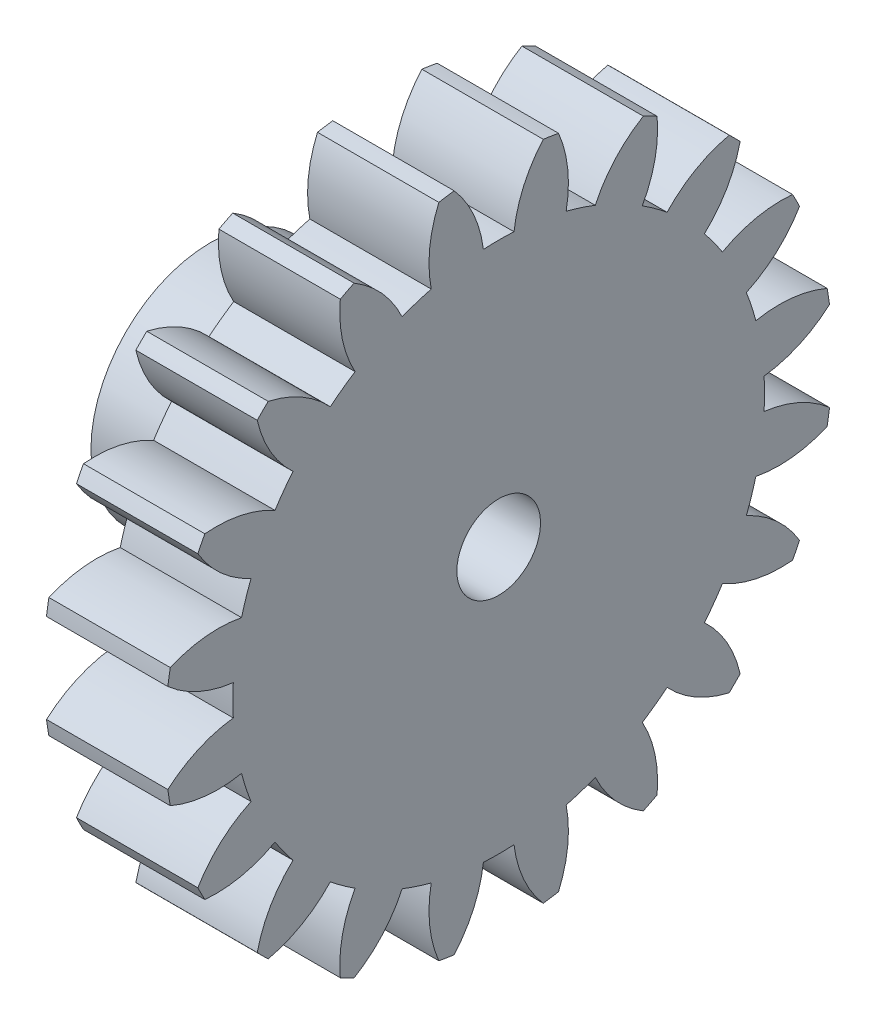
from build123d import *

# Parameters (mm, degrees)
BASPROSKE_W         = 5.08
BASPROSKE_H         = 13.97
TOOTHCUT_DEPTH      = 21.399220573
TEETHCUTS_COUNT     = 20
TEETHCUTS_ANGLE     = 342
BORSKE_R            = 1.750000056
BORE_DEPTH          = 50.8000508
SKETCH1_R           = 5
SKETCH1_R_2         = 1.750000056
BOSS_EXTRUDE1_DEPTH = 6.985
SKETCH3_R           = 3
CUT_EXTRUDE1_DEPTH  = 3.81
BOSS_EXTRUDE2_DEPTH = 3.81
CIRPATTERN1_COUNT   = 36


with BuildPart() as part:
    # BasProSke → Base-Revolve (revolve)
    with BuildSketch(Plane(origin=(0, 0, 0), x_dir=(1, 0, 0), z_dir=(0, 1, 0)), mode=Mode.PRIVATE) as base_revolve_sk:
        with Locations((2.54, 6.985)):
            Rectangle(BASPROSKE_W, BASPROSKE_H)
    revolve(base_revolve_sk.sketch.rotate(Axis((-10, 0, 0), (1, 0, 0)), 180), axis=Axis((-10, 0, 0), (1, 0, 0)))

    # TooCutSke → ToothCut (cut, through all)
    with BuildSketch(Plane(origin=(0, 0, 0), x_dir=(0, 0, -1), z_dir=(1, 0, 0))):
        with BuildLine():
            ThreePointArc((0.64046545, 11.106749257), (0, 11.1252), (-0.64046545, 11.106749257))
            ThreePointArc((-0.64046545, 11.106749257), (-1.052455812, 12.582227662), (-1.8855699, 13.867798935))
            ThreePointArc((-1.8855699, 13.867798935), (0, 13.9954), (1.8855699, 13.867798935))
            ThreePointArc((1.8855699, 13.867798935), (1.052455812, 12.582227662), (0.64046545, 11.106749257))
        make_face()
    toothcut = extrude(amount=TOOTHCUT_DEPTH, mode=Mode.SUBTRACT)

    # TeethCuts: ToothCut ×20 about axis
    teethcuts_axis = Axis((-10, 0, 0), (1, 0, 0))
    for i in range(1, TEETHCUTS_COUNT):
        add(toothcut.rotate(teethcuts_axis, i * TEETHCUTS_ANGLE / (TEETHCUTS_COUNT - 1)), mode=Mode.SUBTRACT)

    # BorSke → Bore (cut, symmetric)
    with BuildSketch(Plane(origin=(0, 0, 0), x_dir=(0, 0, -1), z_dir=(1, 0, 0))):
        with Locations(Location((0, 0, 0), (0, 0, 180))):
            Circle(BORSKE_R)
    extrude(amount=BORE_DEPTH, both=True, mode=Mode.SUBTRACT)

    # Sketch1 → Boss-Extrude1 (add)
    with BuildSketch(Plane.ZY):
        with Locations(Location((0, 0, 0), (0, 0, 180))):
            Circle(SKETCH1_R)
        Circle(SKETCH1_R_2, mode=Mode.SUBTRACT)
    extrude(amount=BOSS_EXTRUDE1_DEPTH)

    # Sketch3 → Cut-Extrude1 (cut)
    with BuildSketch(Plane.ZY.offset(6.985)):
        Circle(SKETCH3_R)
    extrude(amount=-CUT_EXTRUDE1_DEPTH, mode=Mode.SUBTRACT)

    # Sketch4 → Boss-Extrude2 (add)
    with BuildSketch(Plane.ZY.offset(6.985)):
        Polygon((-0.25, 3.127), (0.25, 3.127), (0, 2.693987298), align=None)
    boss_extrude2 = extrude(amount=-BOSS_EXTRUDE2_DEPTH)

    # CirPattern1: Boss-Extrude2 ×36 about axis
    cirpattern1_axis = Axis((0, 0, 0), (1, 0, 0))
    for i in range(1, CIRPATTERN1_COUNT):
        add(boss_extrude2.rotate(cirpattern1_axis, i * 360 / CIRPATTERN1_COUNT))


solid = part.part
